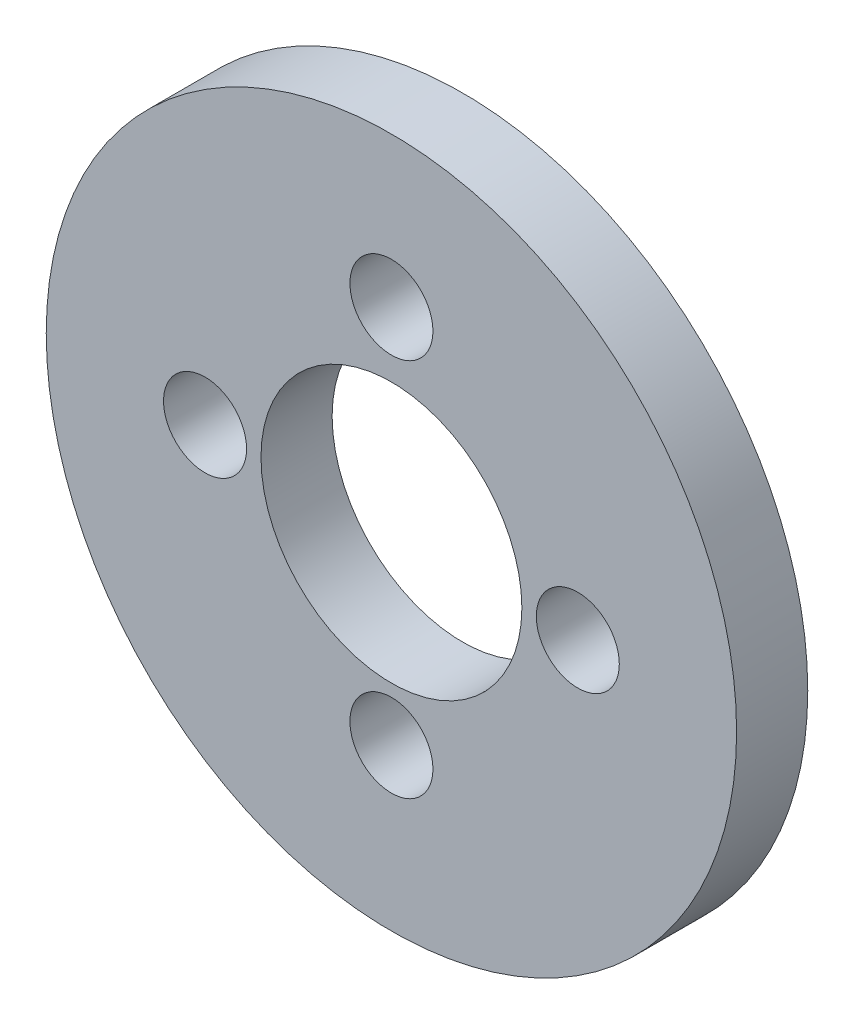
from build123d import *

# Parameters (mm, degrees)
SKETCH1_R           = 14.554642106
SKETCH1_R_2         = 1.75
BOSS_EXTRUDE1_DEPTH = 3
SKETCH2_R           = 5.5
CUT_EXTRUDE1_DEPTH  = 3


with BuildPart() as part:
    # Sketch1 → Boss-Extrude1 (new body)
    with BuildSketch(Plane.XY):
        Circle(SKETCH1_R)
        with Locations((0, 8.228052911)):
            Circle(SKETCH1_R_2, mode=Mode.SUBTRACT)
        with Locations((-7.85825278, 0)):
            Circle(SKETCH1_R_2, mode=Mode.SUBTRACT)
        with Locations((0, -7.765802747)):
            Circle(SKETCH1_R_2, mode=Mode.SUBTRACT)
        with Locations((7.85825278, 0)):
            Circle(SKETCH1_R_2, mode=Mode.SUBTRACT)
    extrude(amount=BOSS_EXTRUDE1_DEPTH)

    # Sketch2 → Cut-Extrude1 (cut)
    with BuildSketch(Plane.XY.offset(3)):
        Circle(SKETCH2_R)
    extrude(amount=-CUT_EXTRUDE1_DEPTH, mode=Mode.SUBTRACT)


solid = part.part
